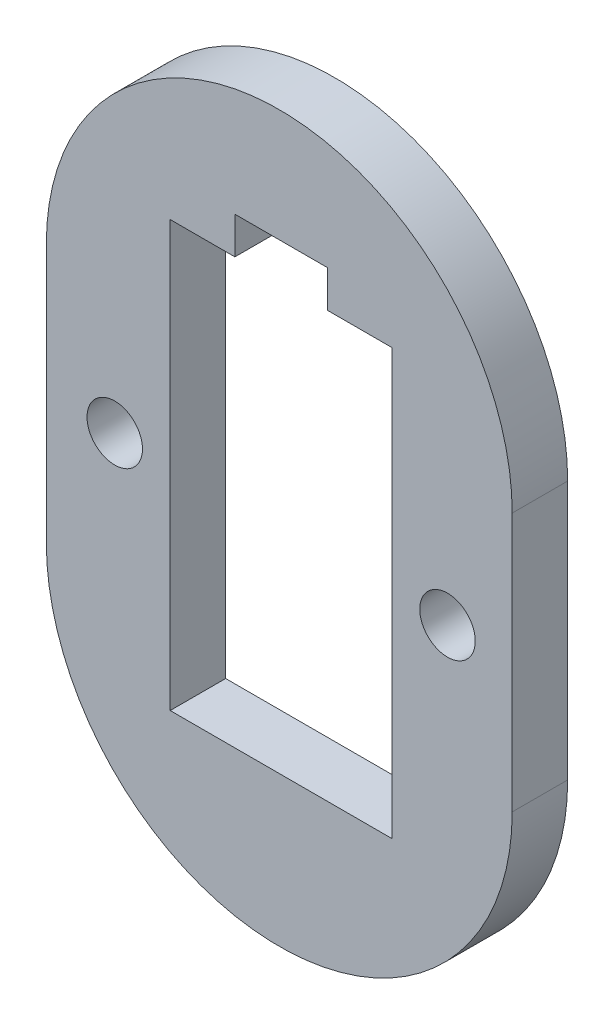
from build123d import *

# Parameters (mm, degrees)
MODEL_R             = 1.5
BOSS_EXTRUDE1_DEPTH = 3


with BuildPart() as part:
    # Model → Boss-Extrude1 (new body)
    with BuildSketch(Plane.XY):
        with BuildLine():
            Line((0.88624, 25.209089561), (0.88624, 11.208991882))
            ThreePointArc((0.88624, 11.208991882), (13.486238839, -1.391009279), (26.08624, 11.20898956))
            Line((26.08624, 11.20898956), (26.08624, 16.208989561))
            Line((26.08624, 16.208989561), (26.08624, 25.208989561))
            ThreePointArc((26.08624, 25.208989561), (13.48629, 37.809039561), (0.88624, 25.209089561))
        make_face()
        with Locations((4.586289997, 18.209039557)):
            Circle(MODEL_R, mode=Mode.SUBTRACT)
        with Locations((22.586289997, 18.209039557)):
            Circle(MODEL_R, mode=Mode.SUBTRACT)
        Polygon((19.58624, 6.708989561), (19.58624, 29.708989561), (16.08624, 29.708989561), (16.08624, 31.708989561), (11.08624, 31.708989561), (11.08624, 29.708989561), (7.58624, 29.708989561), (7.58624, 6.708989561), align=None, mode=Mode.SUBTRACT)
    extrude(amount=BOSS_EXTRUDE1_DEPTH)


solid = part.part
